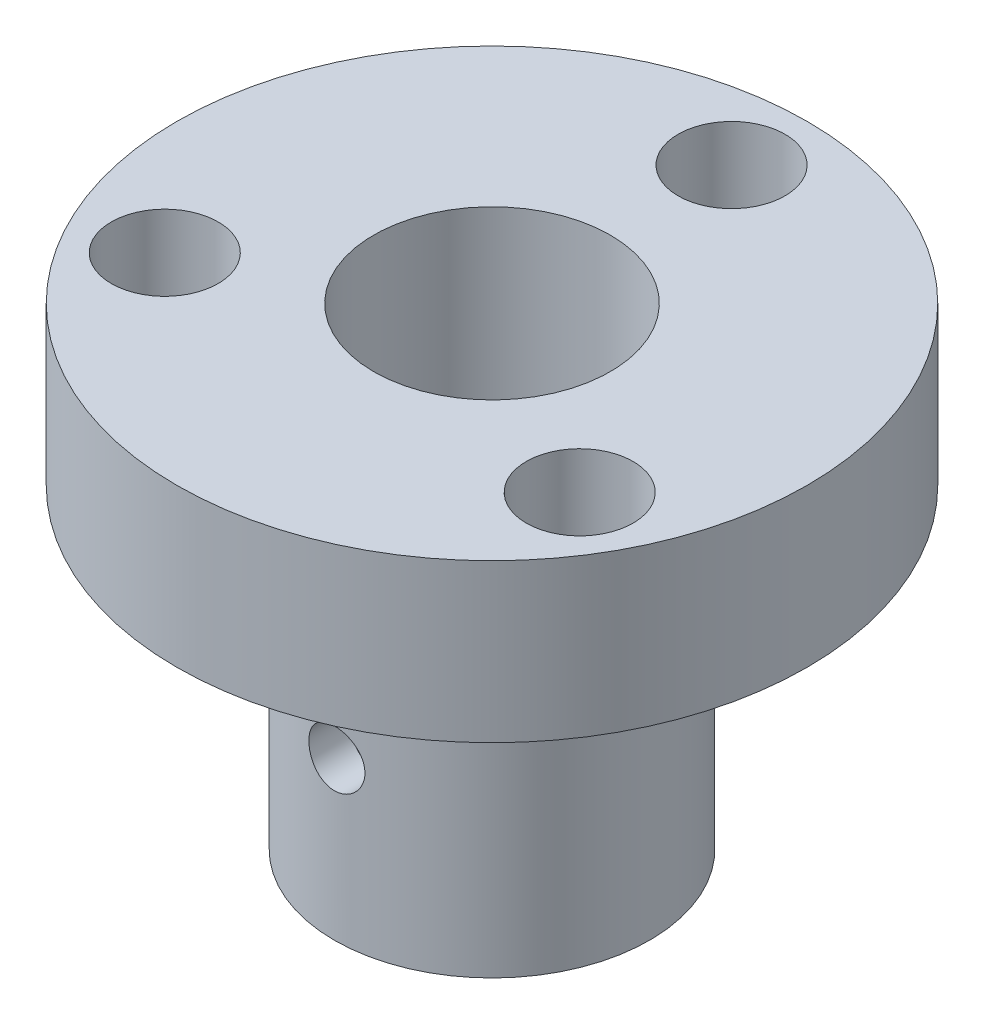
from build123d import *

# Parameters (mm, degrees)
SKETCH1_R                        = 6.35
BOSS_EXTRUDE1_DEPTH              = 12.7
SKETCH2_R                        = 12.7
BOSS_EXTRUDE2_DEPTH              = 6.35
SKETCH3_R                        = 4.76758
CUT_EXTRUDE1_DEPTH               = 20.05
F_18_0_1695_DIAMETER_HOLE1_D     = 4.3053
F_18_0_1695_DIAMETER_HOLE1_DEPTH = 25.4
F_18_0_1695_DIAMETER_HOLE1_TIP   = 1.293442612


with BuildPart() as part:
    # Sketch1 → Boss-Extrude1 (new body)
    with BuildSketch(Plane(origin=(0, 0, 0), x_dir=(1, 0, 0), z_dir=(0, 1, 0))):
        Circle(SKETCH1_R)
    extrude(amount=BOSS_EXTRUDE1_DEPTH)

    # Sketch2 → Boss-Extrude2 (add)
    with BuildSketch(Plane(origin=(0, 12.7, 0), x_dir=(1, 0, 0), z_dir=(0, 1, 0))):
        Circle(SKETCH2_R)
    extrude(amount=BOSS_EXTRUDE2_DEPTH)

    # Sketch3 → Cut-Extrude1 (cut, through all)
    with BuildSketch(Plane(origin=(0, 19.05, 0), x_dir=(1, 0, 0), z_dir=(0, 1, 0))):
        Circle(SKETCH3_R)
    extrude(amount=-CUT_EXTRUDE1_DEPTH, mode=Mode.SUBTRACT)

    # #18 (0.1695) Diameter Hole1
    with Locations(Plane(origin=(0, 19.05, 0), x_dir=(1, 0, 0), z_dir=(0, 1, 0))):
        with Locations((0, 9.652), (-8.358877197, -4.826), (8.358877197, -4.826)):
            Hole(F_18_0_1695_DIAMETER_HOLE1_D / 2, depth=F_18_0_1695_DIAMETER_HOLE1_DEPTH)
            with Locations((0, 0, -(F_18_0_1695_DIAMETER_HOLE1_DEPTH + F_18_0_1695_DIAMETER_HOLE1_TIP / 2))):  # 118° drill point
                Cone(0, F_18_0_1695_DIAMETER_HOLE1_D / 2, F_18_0_1695_DIAMETER_HOLE1_TIP, mode=Mode.SUBTRACT)

    # Sketch8 → #43 (0.089) Diameter Hole1 (revolve, cut)
    with BuildSketch(Plane(origin=(0, 6.35, 0), x_dir=(0, 1, 0), z_dir=(1, 0, 0))):
        Polygon((0, 0), (0, 26.079152758), (1.1303, 25.4), (1.1303, 0), align=None)
    revolve(axis=Axis((0, 6.35, -6.35), (0, 0, 1)), mode=Mode.SUBTRACT)


solid = part.part
